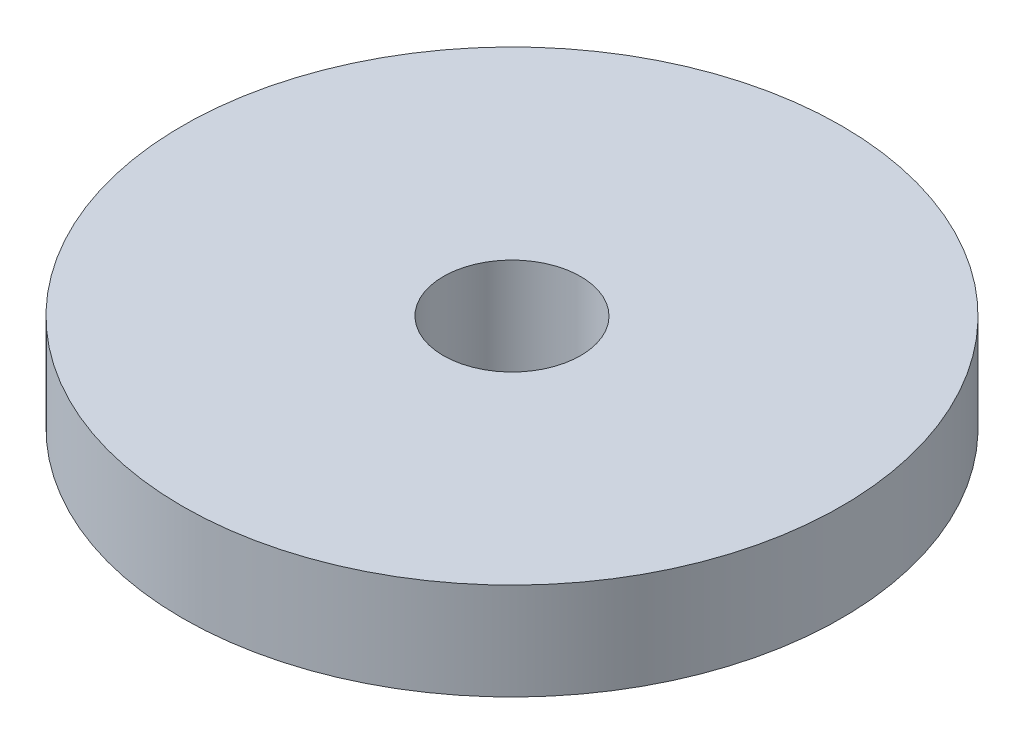
from build123d import *

# Parameters (mm, degrees)
SKETCH1_R                 = 10.795
BOSS_EXTRUDE1_DEPTH       = 3.175
F_8_CLEARANCE_HOLE1_D     = 4.4958
F_8_CLEARANCE_HOLE1_DEPTH = 10.16
F_8_CLEARANCE_HOLE1_TIP   = 1.350674586


with BuildPart() as part:
    # Sketch1 → Boss-Extrude1 (new body)
    with BuildSketch(Plane(origin=(0, 0, 0), x_dir=(1, 0, 0), z_dir=(0, 1, 0))):
        Circle(SKETCH1_R)
    extrude(amount=BOSS_EXTRUDE1_DEPTH)

    # #8 Clearance Hole1
    with Locations(Plane.ZX.offset(3.175)):
        with Locations((0, 0)):
            Hole(F_8_CLEARANCE_HOLE1_D / 2, depth=F_8_CLEARANCE_HOLE1_DEPTH)
            with Locations((0, 0, -(F_8_CLEARANCE_HOLE1_DEPTH + F_8_CLEARANCE_HOLE1_TIP / 2))):  # 118° drill point
                Cone(0, F_8_CLEARANCE_HOLE1_D / 2, F_8_CLEARANCE_HOLE1_TIP, mode=Mode.SUBTRACT)


solid = part.part
